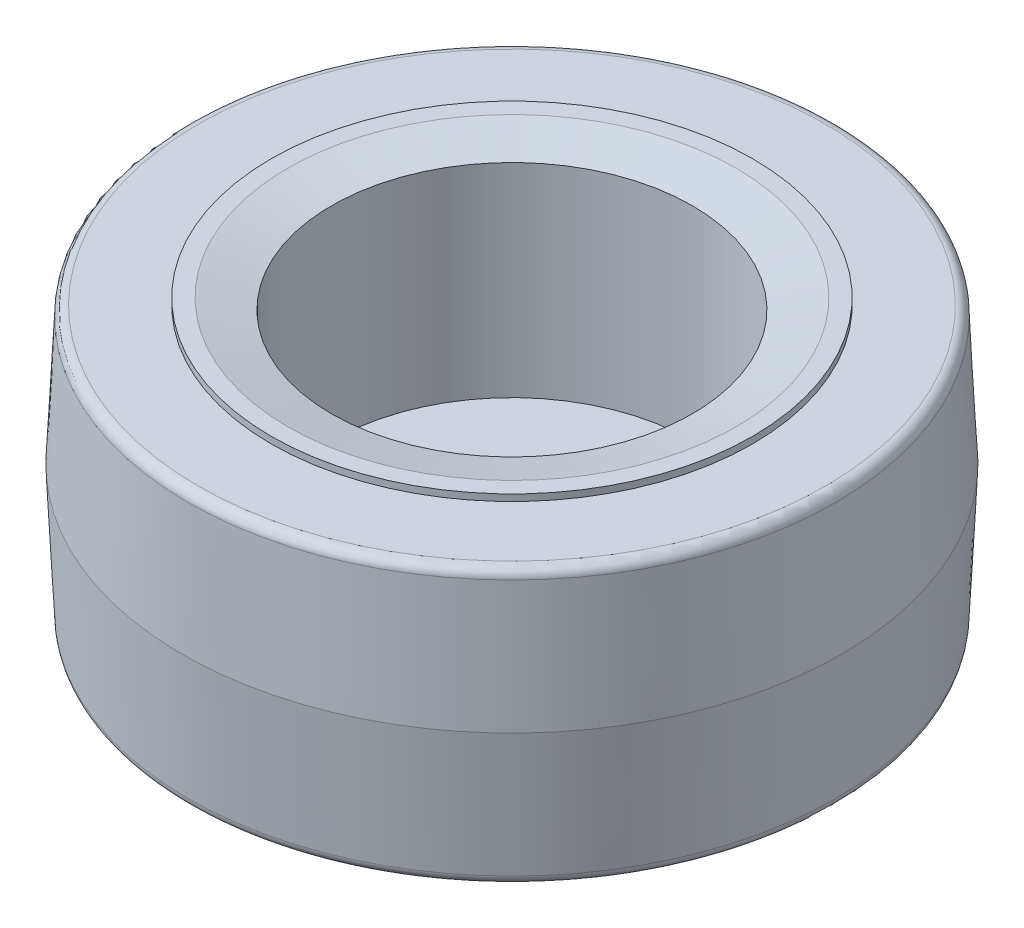
from build123d import *

# Parameters (mm, degrees)
FILLET1_R          = 0.762
SKETCH3_R          = 13.90015
CUT_EXTRUDE1_DEPTH = 16.51


with BuildPart() as part:
    # Sketch2 → Revolve1 (revolve)
    with BuildSketch(Plane.XY, mode=Mode.PRIVATE) as revolve1_sk:
        with BuildLine():
            Line((6.35, -11.1125), (6.35, 11.1125))
            Line((6.35, 11.1125), (8.89, 11.1125))
            ThreePointArc((8.89, 11.1125), (9.690049959, 10.948371533), (10.360856835, 10.482500061))
            ThreePointArc((10.360856835, 10.482500061), (11.258914316, 9.934904036), (12.310452921, 9.909700708))
            Line((12.310452921, 9.909700708), (17.272, 11.1125))
            Line((17.272, 11.1125), (18.542, 11.1125))
            Line((18.542, 11.1125), (18.542, 10.6045))
            Line((18.542, 10.6045), (24.892, 10.6045))
            Line((24.892, 10.6045), (25.4, 0))
            Line((25.4, 0), (24.892, -10.6045))
            Line((24.892, -10.6045), (18.542, -10.6045))
            Line((18.542, -10.6045), (18.542, -11.1125))
            Line((18.542, -11.1125), (17.272, -11.1125))
            Line((17.272, -11.1125), (12.310452921, -9.909700708))
            ThreePointArc((12.310452921, -9.909700708), (11.258914316, -9.934904036), (10.360856835, -10.482500061))
            ThreePointArc((10.360856835, -10.482500061), (9.690049959, -10.948371533), (8.89, -11.1125))
            Line((8.89, -11.1125), (6.35, -11.1125))
        make_face()
    revolve(revolve1_sk.sketch.rotate(Axis((0, 0, 0), (0, 1, 0)), 90), axis=Axis((0, 0, 0), (0, 1, 0)))  # turned: the seam where the file's is

    # Fillet1
    fillet1_edges = [part.edges().sort_by_distance(p)[0] for p in [
        (0, -10.6045, 24.892),
        (0, 10.6045, 24.892),
    ]]
    fillet(fillet1_edges, radius=FILLET1_R)

    # Sketch3 → Cut-Extrude1 (cut)
    with BuildSketch(Plane(origin=(0, 11.1125, 0), x_dir=(-1, 0, 0), z_dir=(0, 1, 0))):
        with Locations(Location((0, 0, 0), (0, 0, 90))):  # turned: the seam where the file's is
            Circle(SKETCH3_R)
    extrude(amount=-CUT_EXTRUDE1_DEPTH, mode=Mode.SUBTRACT)


solid = part.part
